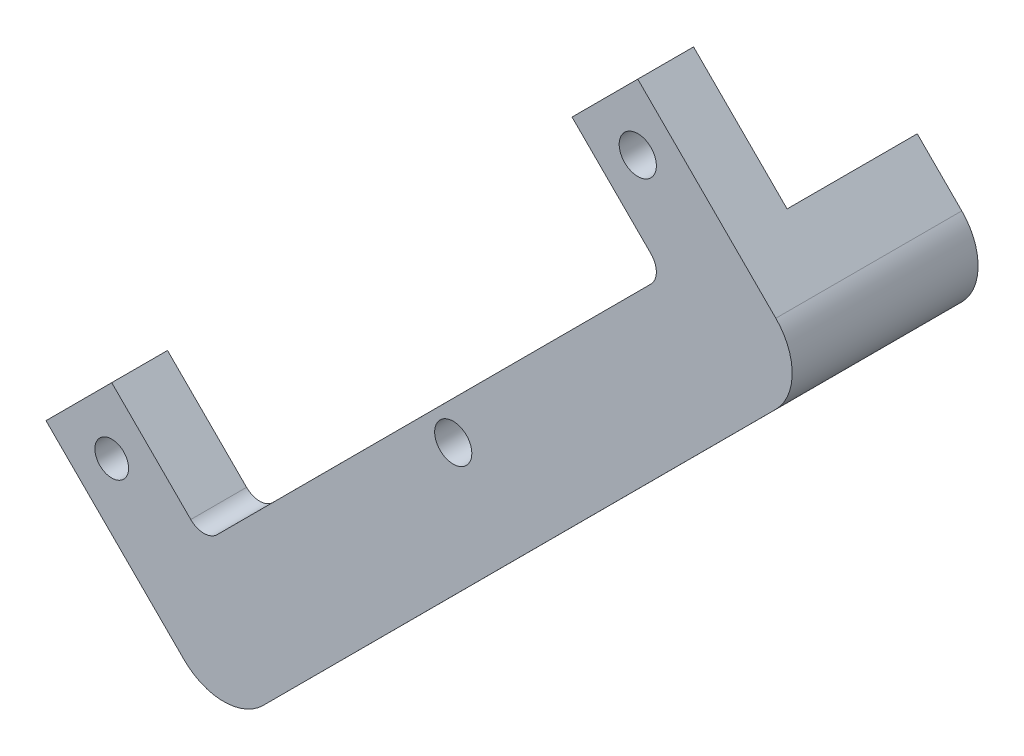
from build123d import *

# Parameters (mm, degrees)
SKETCH1_R                         = 6.35
BASE_EXTRUDE_DEPTH                = 63.5
SKETCH2_W                         = 45.301656397
SKETCH2_H                         = 44.45
CUT_EXTRUDE1_DEPTH                = 324.049195456
F_1_2_20_TAPPED_HOLE4_D           = 11.50874
F_1_2_20_TAPPED_HOLE3_D           = 11.50874
F_1_2_20_TAPPED_HOLE3_CBORE_D     = 12.7
F_1_2_20_TAPPED_HOLE3_CBORE_DEPTH = 25.4
F_1_2_20_TAPPED_HOLE1_D           = 12.7
F_1_2_20_TAPPED_HOLE2_D           = 11.50874


with BuildPart() as part:
    # Sketch1 → Base-Extrude (new body)
    with BuildSketch(Plane.XY):
        with BuildLine():
            Line((-87.034046036, -176.655263526), (-109.476853925, -199.11373351))
            Line((-109.476853925, -199.11373351), (-62.270703318, -246.286963476))
            ThreePointArc((-62.270703318, -246.286963476), (-48.800588675, -251.86188097), (-35.333068284, -246.280699366))
            Line((-35.333068284, -246.280699366), (139.761564896, -71.145344736))
            ThreePointArc((139.761564896, -71.145344736), (145.339614596, -57.676526855), (139.761564896, -44.207708974))
            Line((139.761564896, -44.207708974), (124.048977285, -28.491467114))
            Line((124.048977285, -28.491467114), (92.616039983, 2.948780491))
            Line((92.616039983, 2.948780491), (70.168405011, -19.504866145))
            Line((70.168405011, -19.504866145), (97.107164721, -46.449890955))
            ThreePointArc((97.107164721, -46.449890955), (98.966514621, -50.939440985), (97.107243808, -55.429023769))
            Line((97.107243808, -55.429023769), (-51.056538279, -203.63248535))
            ThreePointArc((-51.056538279, -203.63248535), (-55.545734899, -205.492958311), (-60.035829043, -203.634652493))
            Line((-60.035829043, -203.634652493), (-87.034046036, -176.655263526))
        make_face()
        with Locations((29.591473015, -136.091254995)):
            Circle(SKETCH1_R, mode=Mode.SUBTRACT)
    extrude(amount=BASE_EXTRUDE_DEPTH)

    # Sketch2 → Cut-Extrude1 (cut, through all)
    with BuildSketch(Plane(origin=(-154.257082678, -154.364733609, 0), x_dir=(0.707353385, -0.706860091, 0), z_dir=(-0.706860091, -0.707353385, 0))):
        with Locations((85.957556745, 22.225)):
            Rectangle(SKETCH2_W, SKETCH2_H)
    extrude(amount=-CUT_EXTRUDE1_DEPTH, mode=Mode.SUBTRACT)

    # 1/2-20 Tapped Hole4 (through all)
    with Locations(Plane.XY.offset(63.5)):
        with Locations((-87.026214989, -199.105902462)):
            Hole(F_1_2_20_TAPPED_HOLE4_D / 2)

    # 1/2-20 Tapped Hole3 (through all)
    with Locations(Plane.XY.offset(63.5)):
        with Locations((92.616237749, -19.504668428)):
            CounterBoreHole(F_1_2_20_TAPPED_HOLE3_D / 2, F_1_2_20_TAPPED_HOLE3_CBORE_D / 2, F_1_2_20_TAPPED_HOLE3_CBORE_DEPTH)

    # 1/2-20 Tapped Hole1 (through all)
    with Locations(Plane(origin=(105.469704015, -105.445180815, 0), x_dir=(0, 0, -1), z_dir=(0.707188992, -0.707024561, 0))):
        with Locations((-25.4, 16.751653867)):
            Hole(F_1_2_20_TAPPED_HOLE1_D / 2)

    # 1/2-20 Tapped Hole2 (through all)
    with Locations(Plane(origin=(105.469704015, -105.445180815, 0), x_dir=(0, 0, -1), z_dir=(0.707188992, -0.707024561, 0))):
        with Locations((-25.4, -167.398346133)):
            Hole(F_1_2_20_TAPPED_HOLE2_D / 2)


solid = part.part
